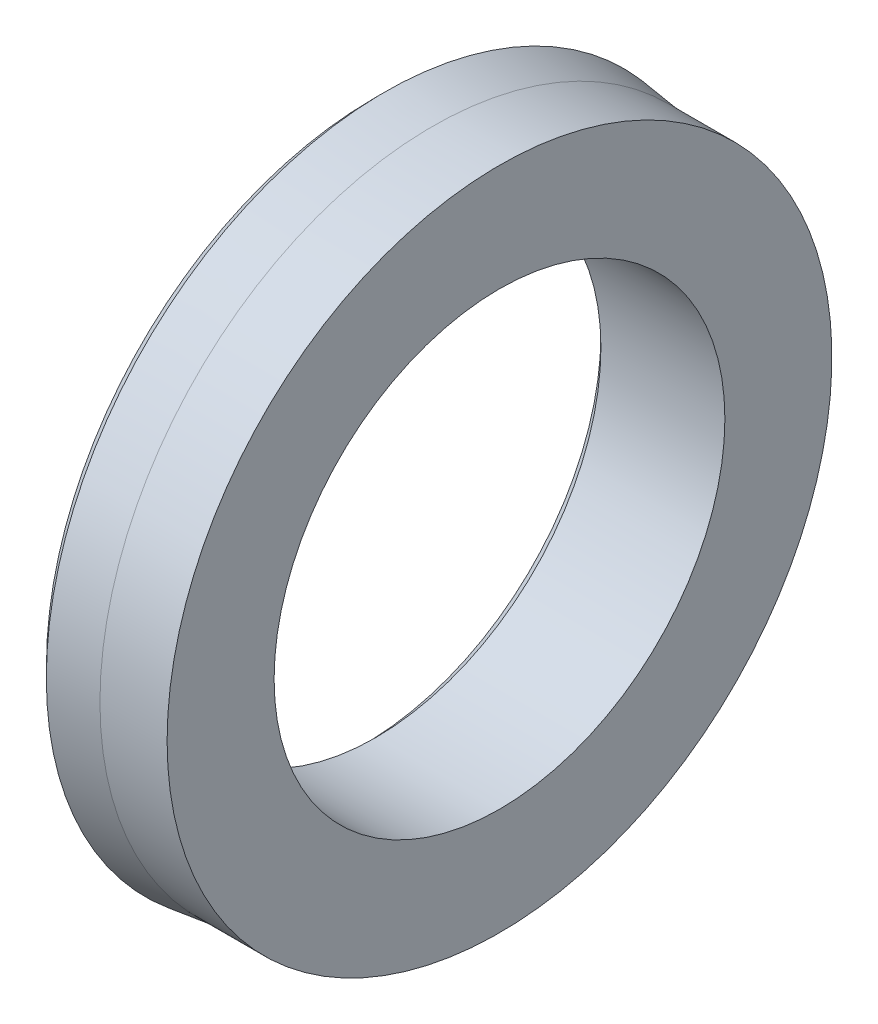
from build123d import *


with BuildPart() as part:
    # Sketch1 → Revolve1 (revolve)
    with BuildSketch(Plane.XY):
        with BuildLine():
            Line((2.983876441, 24), (2.983876441, 21))
            Line((2.983876441, 21), (3.983876441, 20))
            Line((3.983876441, 20), (14.983876441, 20))
            Line((14.983876441, 20), (14.983876441, 29.495))
            Line((14.983876441, 29.495), (9.023876441, 29.495))
            Line((9.023876441, 29.495), (4.783876441, 30.014855378))
            Line((4.783876441, 30.014855378), (3.783876441, 29))
            Line((3.783876441, 29), (3.783876441, 26.245704095))
            Line((3.783876441, 26.245704095), (7.463876441, 25.794508861))
            ThreePointArc((7.463876441, 25.794508861), (8.361130872, 24.89725443), (7.463876441, 24))
            Line((7.463876441, 24), (2.983876441, 24))
        make_face()
    revolve(axis=Axis((0, 0, 0), (1, 0, 0)))


solid = part.part
